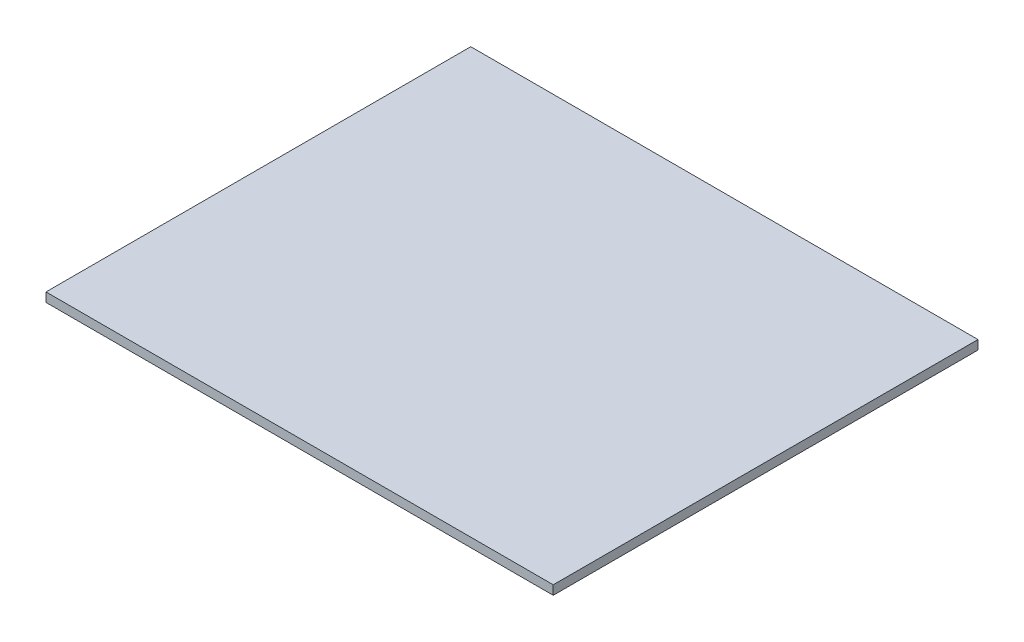
from build123d import *

# Parameters (mm, degrees)
SKETCH1_W           = 111.098761939
SKETCH1_H           = 93.0339226
BOSS_EXTRUDE1_DEPTH = 2


with BuildPart() as part:
    # Sketch1 → Boss-Extrude1 (new body)
    with BuildSketch(Plane(origin=(0, 0, 0), x_dir=(1, 0, 0), z_dir=(0, 1, 0))):
        with Locations((55.54938097, 46.5169613)):
            Rectangle(SKETCH1_W, SKETCH1_H)
    extrude(amount=BOSS_EXTRUDE1_DEPTH)


solid = part.part
